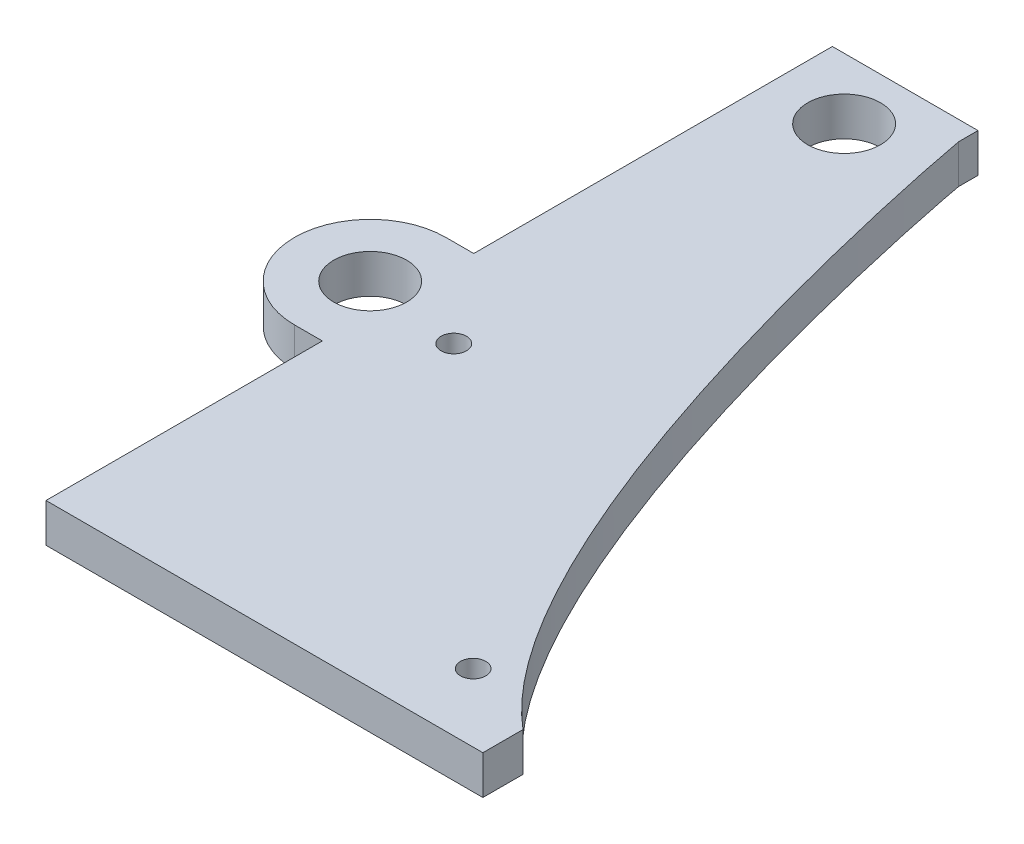
from build123d import *

# Parameters (mm, degrees)
SKETCH1_R               = 4.7625
BOSS_EXTRUDE1_DEPTH     = 5.08
SKETCH4_W               = 19.05
SKETCH4_H               = 5.08
BOSS_EXTRUDE2_DEPTH     = 5.08
SKETCH5_R               = 1.660728382
SKETCH5_R_2             = 1.651
CUT_EXTRUDE1_DEPTH      = 1.0000001
CUT_EXTRUDE1_DEPTH_BACK = 6.0800001
SKETCH6_R               = 4.7625
BOSS_EXTRUDE3_DEPTH     = 5.08
SKETCH8_R               = 4.7625
CUT_EXTRUDE2_DEPTH      = 6.0800001
SKETCH9_W               = 19.05
SKETCH9_H               = 5.08
CUT_EXTRUDE3_DEPTH      = 1.0000001
CUT_EXTRUDE3_DEPTH_BACK = 6.0800001
CUT_EXTRUDE4_DEPTH      = 1.0000001
CUT_EXTRUDE4_DEPTH_BACK = 6.0800001


with BuildPart() as part:
    # Sketch1 → Boss-Extrude1 (new body)
    with BuildSketch(Plane(origin=(0, 0, 0), x_dir=(1, 0, 0), z_dir=(0, 1, 0))):
        with BuildLine():
            Line((-9.525, 53.975), (9.525, 53.975))
            Line((9.525, 53.975), (9.525, 51.435))
            add(Edge.make_bspline(
                [(9.525, 51.435), (9.525, 51.21454564), (27.819109584, -48.895), (60.325, -48.895)],
                knots=[0, 0, 0, 0, 1, 1, 1, 1], degree=3))
            Line((60.325, -48.895), (-9.525, -48.895))
            Line((-9.525, -48.895), (-9.525, 53.975))
        make_face()
        with Locations((0, 45.9867)):
            Circle(SKETCH1_R, mode=Mode.SUBTRACT)
    extrude(amount=BOSS_EXTRUDE1_DEPTH)

    # Sketch4 → Boss-Extrude2 (add)
    with BuildSketch(Plane(origin=(0, 5.08, 0), x_dir=(1, 0, 0), z_dir=(0, 1, 0))):
        with Locations((50.8, -51.435)):
            Rectangle(SKETCH4_W, SKETCH4_H)
    extrude(amount=-BOSS_EXTRUDE2_DEPTH)

    # Sketch5 → Cut-Extrude1 (cut, two sides)
    with BuildSketch(Plane.XZ) as cut_extrude1_sk:
        with Locations((-0.635, 4.445)):
            Circle(SKETCH5_R)
        with Locations((37.465, 40.005)):
            Circle(SKETCH5_R_2)
    extrude(amount=CUT_EXTRUDE1_DEPTH, mode=Mode.SUBTRACT)
    extrude(cut_extrude1_sk.sketch, amount=-CUT_EXTRUDE1_DEPTH_BACK, mode=Mode.SUBTRACT)

    # Sketch6 → Boss-Extrude3 (add)
    with BuildSketch(Plane.XZ):
        with BuildLine():
            Line((-13.170662, 12.74826), (-9.525, 12.74826))
            Line((-9.525, 12.74826), (-9.525, 12.053013747))
            ThreePointArc((-9.525, 12.053013747), (-3.264662, 2.84226), (-9.525, -6.368493747))
            Line((-9.525, -6.368493747), (-9.525, -7.06374))
            Line((-9.525, -7.06374), (-13.170662, -7.06374))
            ThreePointArc((-13.170662, -7.06374), (-23.076662, 2.84226), (-13.170662, 12.74826))
        make_face()
        with Locations((-13.170662, 2.84226)):
            Circle(SKETCH6_R, mode=Mode.SUBTRACT)
    extrude(amount=-BOSS_EXTRUDE3_DEPTH)

    # Sketch8 → Cut-Extrude2 (cut, through all)
    with BuildSketch(Plane(origin=(0, 5.08, 0), x_dir=(1, 0, 0), z_dir=(0, 1, 0))):
        with Locations((-13.170662, -2.84226)):
            Circle(SKETCH8_R)
    extrude(amount=-CUT_EXTRUDE2_DEPTH, mode=Mode.SUBTRACT)

    # Sketch9 → Cut-Extrude3 (cut, two sides)
    with BuildSketch(Plane.XZ) as cut_extrude3_sk:
        with Locations((50.8, 51.435)):
            Rectangle(SKETCH9_W, SKETCH9_H)
    extrude(amount=CUT_EXTRUDE3_DEPTH, mode=Mode.SUBTRACT)
    extrude(cut_extrude3_sk.sketch, amount=-CUT_EXTRUDE3_DEPTH_BACK, mode=Mode.SUBTRACT)

    # Sketch10 → Cut-Extrude4 (cut, two sides)
    with BuildSketch(Plane.XZ) as cut_extrude4_sk:
        with BuildLine():
            Line((47.625, 43.646486826), (47.625, 48.895))
            Line((47.625, 48.895), (60.325, 48.895))
            add(Edge.make_bspline(
                [(60.325, 48.895), (55.814379896, 48.895), (51.577410685, 46.967369191), (47.625, 43.646486826)],
                knots=[0, 0, 0, 0, 0.138763161, 0.138763161, 0.138763161, 0.138763161], degree=3))
        make_face()
    extrude(amount=CUT_EXTRUDE4_DEPTH, mode=Mode.SUBTRACT)
    extrude(cut_extrude4_sk.sketch, amount=-CUT_EXTRUDE4_DEPTH_BACK, mode=Mode.SUBTRACT)


solid = part.part
